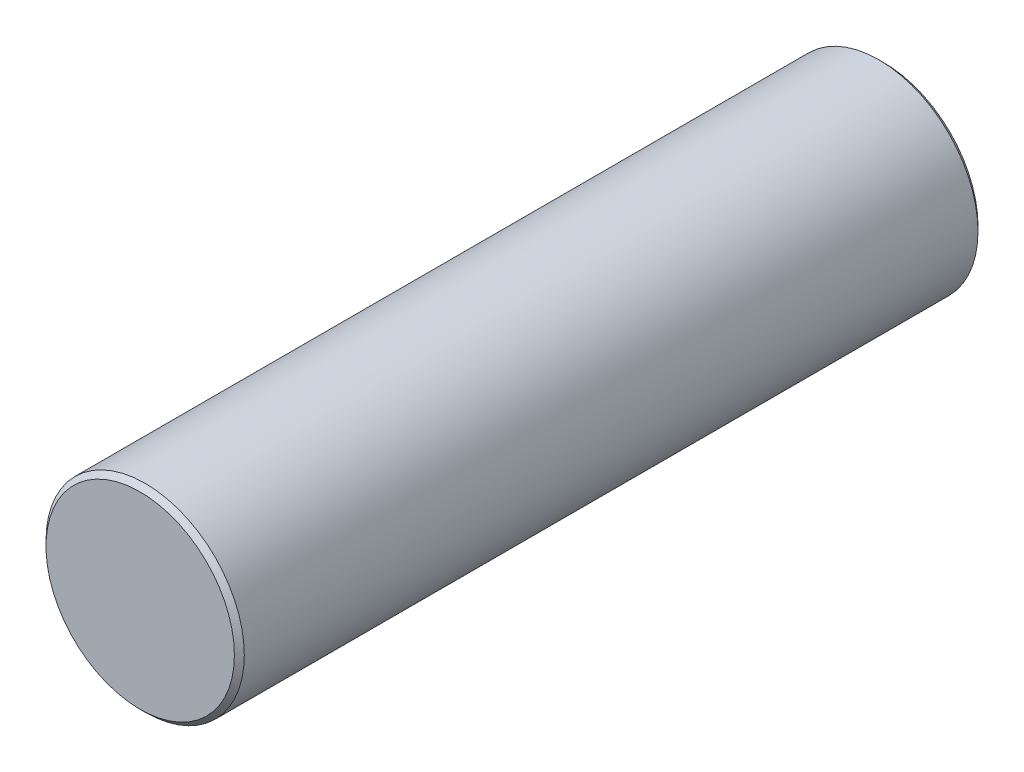
from build123d import *

# Parameters (mm, degrees)
SKETCH1_R           = 20
BOSS_EXTRUDE1_DEPTH = 150
CHAMFER1_SIZE       = 1


with BuildPart() as part:
    # Sketch1 → Boss-Extrude1 (new body)
    with BuildSketch(Plane.XY):
        Circle(SKETCH1_R)
    extrude(amount=BOSS_EXTRUDE1_DEPTH)

    # Chamfer1
    chamfer1_edges = [part.edges().sort_by_distance(p)[0] for p in [
        (-20, 0, 0),
        (-20, 0, 150),
    ]]
    chamfer(chamfer1_edges, length=CHAMFER1_SIZE)


solid = part.part
